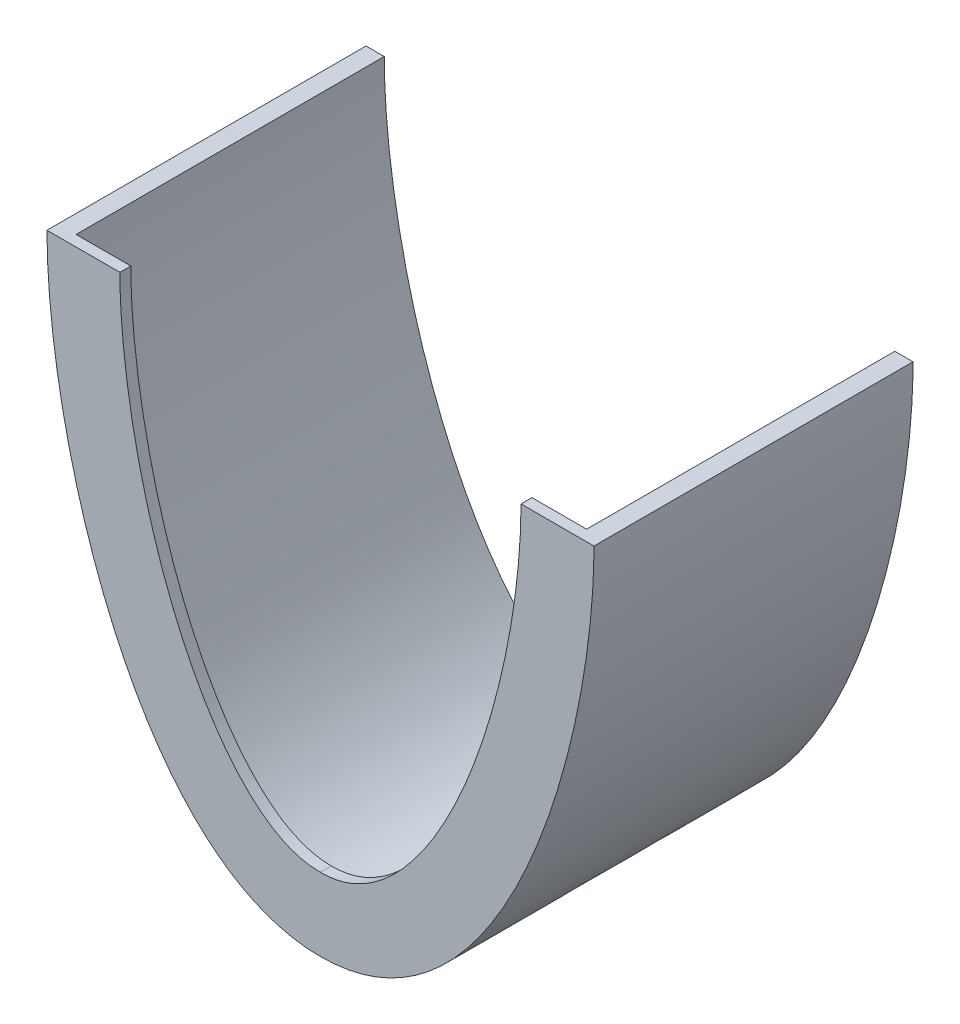
from build123d import *

# Parameters (mm, degrees)
AUFSATZ_LINEAR_AUSTRAGEN1_DEPTH = 87.5
AUFSATZ_LINEAR_AUSTRAGEN2_DEPTH = 3


with BuildPart() as part:
    # Skizze1 → Aufsatz-Linear austragen1 (new body)
    with BuildSketch(Plane.XY):
        with BuildLine():
            Line((70, 135), (75, 135))
            add(Edge.make_bspline(
                [(75, 135), (75, 85), (50, 0), (0, 0)],
                knots=[0, 0, 0, 0, 1, 1, 1, 1], degree=3))
            add(Edge.make_bspline(
                [(-75, 135), (-75, 85), (-50, 0), (0, 0)],
                knots=[0, 0, 0, 0, 1, 1, 1, 1], degree=3))
            Line((-75, 135), (-70, 135))
            add(Edge.make_bspline(
                [(-70, 135), (-70, 134.235830661), (-69.988198773, 132.720199802), (-69.917202304, 129.587823739), (-69.739296677, 125.562483107), (-69.382500239, 120.558234941), (-68.715201745, 113.694150002), (-67.521341452, 104.810166669), (-65.513215882, 93.851236329), (-62.93138243, 82.778515639), (-58.728780272, 68.108322516), (-52.062240515, 50.404871755), (-41.877955392, 31.645588642), (-31.715641804, 19.308664411), (-22.738979919, 12.068615356), (-16.806453993, 8.735416424), (-11.861069454, 6.82776821), (-8.044105662, 5.78641993), (-4.759096765, 5.253592922), (-2.067882529, 5.036787941), (-0.686559974, 5), (0, 5)],
                knots=[0, 0, 0, 0, 0.015625, 0.03125, 0.0625, 0.09375, 0.125, 0.1875, 0.25, 0.3125, 0.375, 0.5, 0.625, 0.75, 0.8125, 0.875, 0.90625, 0.9375, 0.96875, 0.984375, 1, 1, 1, 1], degree=3))
            add(Edge.make_bspline(
                [(0, 5), (0.686559974, 5), (2.067882529, 5.036787941), (4.759096765, 5.253592922), (8.044105662, 5.78641993), (11.861069454, 6.82776821), (16.806453993, 8.735416424), (22.738979919, 12.068615356), (31.715641804, 19.308664411), (41.877955392, 31.645588642), (52.062240515, 50.404871755), (58.728780272, 68.108322516), (62.93138243, 82.778515639), (65.513215882, 93.851236329), (67.521341452, 104.810166669), (68.715201745, 113.694150002), (69.382500239, 120.558234941), (69.739296677, 125.562483107), (69.917202304, 129.587823739), (69.988198773, 132.720199802), (70, 134.235830661), (70, 135)],
                knots=[0, 0, 0, 0, 0.015625, 0.03125, 0.0625, 0.09375, 0.125, 0.1875, 0.25, 0.375, 0.5, 0.625, 0.6875, 0.75, 0.8125, 0.875, 0.90625, 0.9375, 0.96875, 0.984375, 1, 1, 1, 1], degree=3))
        make_face()
    extrude(amount=-AUFSATZ_LINEAR_AUSTRAGEN1_DEPTH)

    # Skizze2 → Aufsatz-Linear austragen2 (add)
    with BuildSketch(Plane.XY):
        with BuildLine():
            Line((70, 135), (55, 135))
            add(Edge.make_bspline(
                [(55, 135), (55, 134.312563404), (54.98944277, 132.953310214), (54.925113314, 130.110337821), (54.76289358, 126.435742077), (54.434270916, 121.822920438), (53.815913608, 115.460227936), (52.702531114, 107.170269874), (50.822416329, 96.908951327), (48.405178534, 86.543556904), (44.485526636, 72.86356396), (38.327293205, 56.53974227), (30.746433554, 42.648576252), (24.179034544, 33.802950237), (19.153055027, 28.451696098), (14.198355808, 24.485177293), (10.244035456, 22.285692178), (7.160226215, 21.099839519), (4.858345366, 20.472776729), (2.886548788, 20.153363317), (1.272736363, 20.022887972), (0.420626518, 20), (0, 20)],
                knots=[0, 0, 0, 0, 0.015625, 0.03125, 0.0625, 0.09375, 0.125, 0.1875, 0.25, 0.3125, 0.375, 0.5, 0.625, 0.6875, 0.75, 0.8125, 0.875, 0.90625, 0.9375, 0.96875, 0.984375, 1, 1, 1, 1], degree=3))
            add(Edge.make_bspline(
                [(0, 20), (-0.420626518, 20), (-1.272736363, 20.022887972), (-2.886548788, 20.153363317), (-4.858345366, 20.472776729), (-7.160226215, 21.099839519), (-10.244035456, 22.285692178), (-14.198355808, 24.485177293), (-19.153055027, 28.451696098), (-24.179034544, 33.802950237), (-30.746433554, 42.648576252), (-38.327293205, 56.53974227), (-44.485526636, 72.86356396), (-48.405178534, 86.543556904), (-50.822416329, 96.908951327), (-52.702531114, 107.170269874), (-53.815913608, 115.460227936), (-54.434270916, 121.822920438), (-54.76289358, 126.435742077), (-54.925113314, 130.110337821), (-54.98944277, 132.953310214), (-55, 134.312563404), (-55, 135)],
                knots=[0, 0, 0, 0, 0.015625, 0.03125, 0.0625, 0.09375, 0.125, 0.1875, 0.25, 0.3125, 0.375, 0.5, 0.625, 0.6875, 0.75, 0.8125, 0.875, 0.90625, 0.9375, 0.96875, 0.984375, 1, 1, 1, 1], degree=3))
            Line((-55, 135), (-70, 135))
            add(Edge.make_bspline(
                [(0, 5), (-0.686559974, 5), (-2.067882529, 5.036787941), (-4.759096765, 5.253592922), (-8.044105662, 5.78641993), (-11.861069454, 6.82776821), (-16.806453993, 8.735416424), (-22.738979919, 12.068615356), (-31.715641804, 19.308664411), (-41.877955392, 31.645588642), (-52.062240515, 50.404871755), (-58.728780272, 68.108322516), (-62.93138243, 82.778515639), (-65.513215882, 93.851236329), (-67.521341452, 104.810166669), (-68.715201745, 113.694150002), (-69.382500239, 120.558234941), (-69.739296677, 125.562483107), (-69.917202304, 129.587823739), (-69.988198773, 132.720199802), (-70, 134.235830661), (-70, 135)],
                knots=[0, 0, 0, 0, 0.015625, 0.03125, 0.0625, 0.09375, 0.125, 0.1875, 0.25, 0.375, 0.5, 0.625, 0.6875, 0.75, 0.8125, 0.875, 0.90625, 0.9375, 0.96875, 0.984375, 1, 1, 1, 1], degree=3))
            add(Edge.make_bspline(
                [(70, 135), (70, 134.235830661), (69.988198773, 132.720199802), (69.917202304, 129.587823739), (69.739296677, 125.562483107), (69.382500239, 120.558234941), (68.715201745, 113.694150002), (67.521341452, 104.810166669), (65.513215882, 93.851236329), (62.93138243, 82.778515639), (58.728780272, 68.108322516), (52.062240515, 50.404871755), (41.877955392, 31.645588642), (31.715641804, 19.308664411), (22.738979919, 12.068615356), (16.806453993, 8.735416424), (11.861069454, 6.82776821), (8.044105662, 5.78641993), (4.759096765, 5.253592922), (2.067882529, 5.036787941), (0.686559974, 5), (0, 5)],
                knots=[0, 0, 0, 0, 0.015625, 0.03125, 0.0625, 0.09375, 0.125, 0.1875, 0.25, 0.3125, 0.375, 0.5, 0.625, 0.75, 0.8125, 0.875, 0.90625, 0.9375, 0.96875, 0.984375, 1, 1, 1, 1], degree=3))
        make_face()
    extrude(amount=-AUFSATZ_LINEAR_AUSTRAGEN2_DEPTH)


solid = part.part
